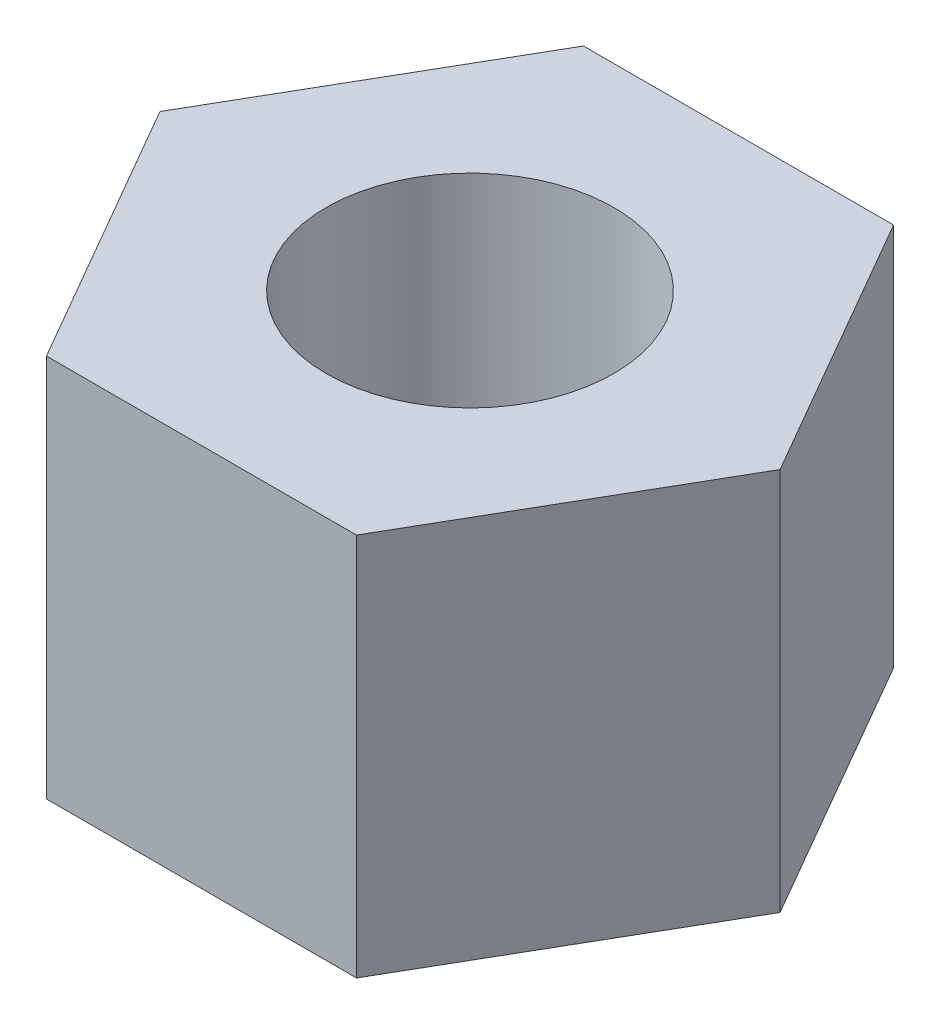
from build123d import *

# Parameters (mm, degrees)
SKETCH_1_R      = 1.5
EXTRUDE_1_DEPTH = 4


with BuildPart() as part:
    # 草图1 → 凸台-拉伸1 (new body)
    with BuildSketch(Plane(origin=(0, 0, 0), x_dir=(1, 0, 0), z_dir=(0, 1, 0))):
        Polygon((3.233161507, 0), (1.616580754, 2.8), (-1.616580754, 2.8), (-3.233161507, 0), (-1.616580754, -2.8), (1.616580754, -2.8), align=None)
        Circle(SKETCH_1_R, mode=Mode.SUBTRACT)
    extrude(amount=EXTRUDE_1_DEPTH)


solid = part.part
